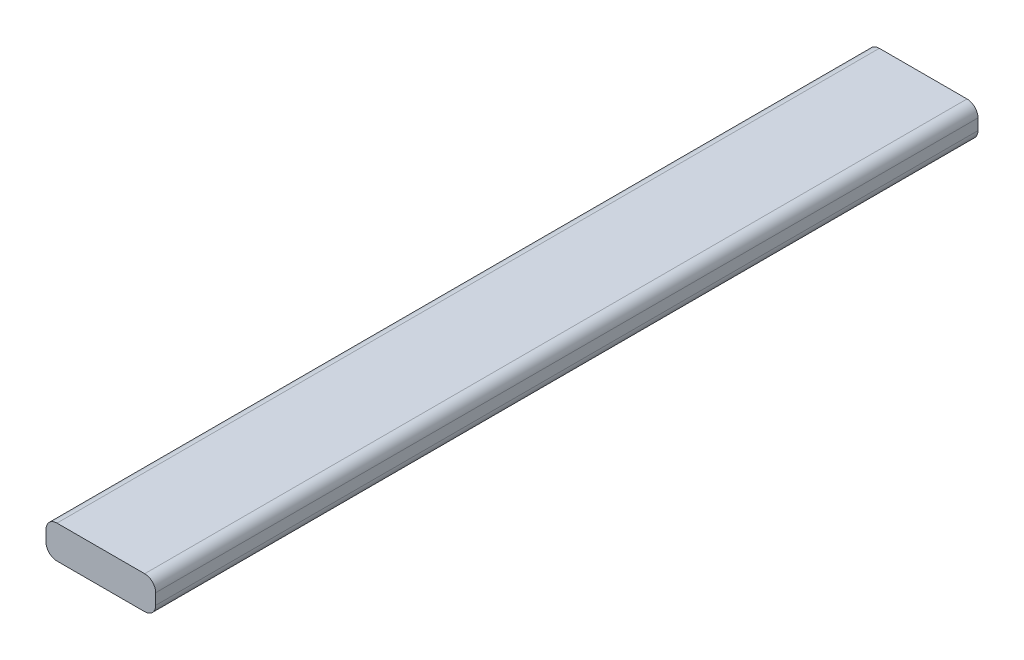
from build123d import *

# Parameters (mm, degrees)
BOSS_EXTRU_1_DEPTH = 75


with BuildPart() as part:
    # Esquisse1 → Boss.-Extru.1 (new body)
    with BuildSketch(Plane.XY):
        with BuildLine():
            Line((-4, 1.5), (4, 1.5))
            ThreePointArc((4, 1.5), (4.707106781, 1.207106781), (5, 0.5))
            Line((5, 0.5), (5, -0.5))
            ThreePointArc((5, -0.5), (4.707106781, -1.207106781), (4, -1.5))
            Line((4, -1.5), (-4, -1.5))
            ThreePointArc((-4, -1.5), (-4.707106781, -1.207106781), (-5, -0.5))
            Line((-5, -0.5), (-5, 0.5))
            ThreePointArc((-5, 0.5), (-4.707106781, 1.207106781), (-4, 1.5))
        make_face()
    extrude(amount=BOSS_EXTRU_1_DEPTH)


solid = part.part
